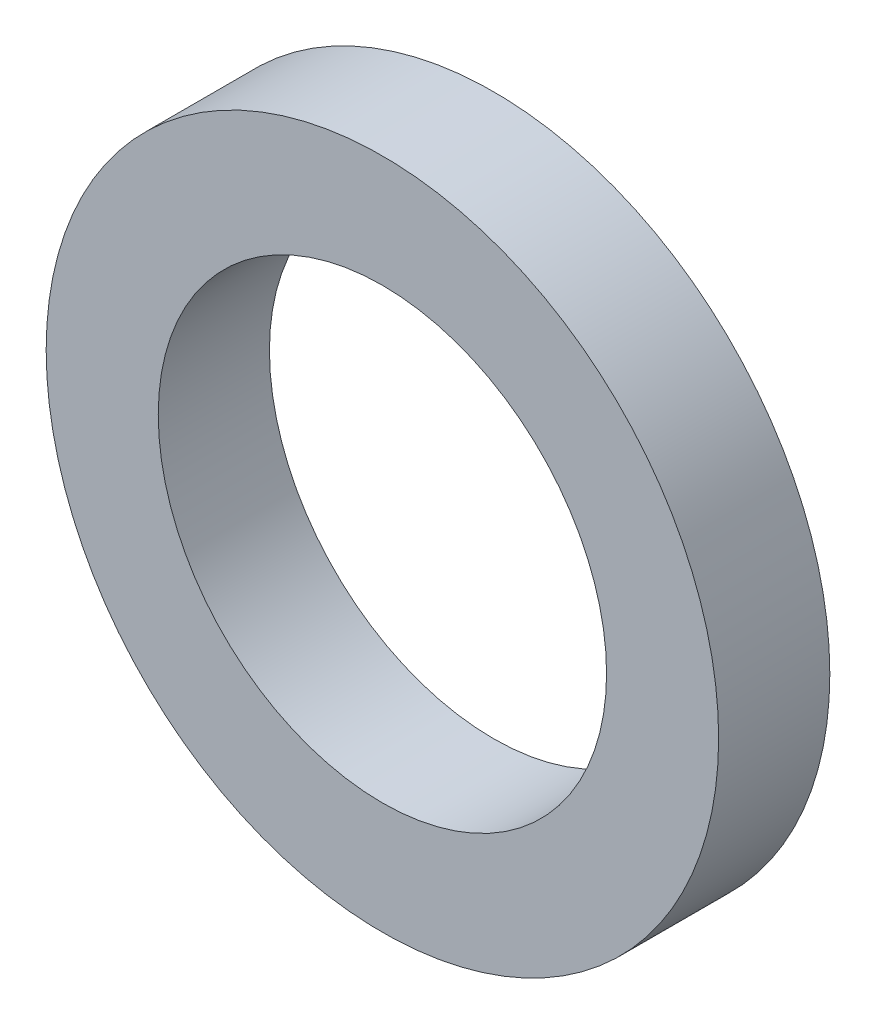
from build123d import *

# Parameters (mm, degrees)
SKETCH1_W = 0.79375
SKETCH1_H = 0.7874


with BuildPart() as part:
    # Sketch1 → Revolve1 (revolve)
    with BuildSketch(Plane(origin=(0, 0, 0), x_dir=(1, 0, 0), z_dir=(0, 1, 0))):
        with Locations((1.984375, -0.3937)):
            Rectangle(SKETCH1_W, SKETCH1_H)
    revolve(axis=Axis((0, 0, 0), (0, 0, 1)))


solid = part.part
